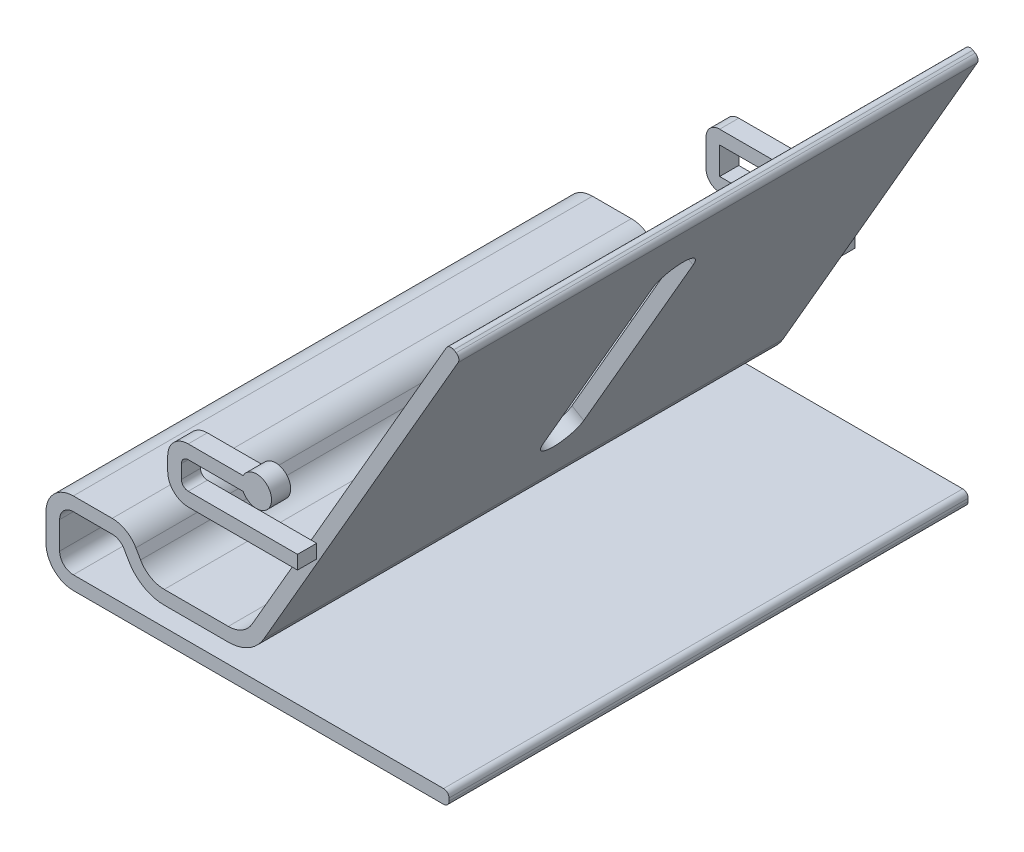
from build123d import *

# Parameters (mm, degrees)
EXTRUDE_12_DEPTH    = 190
CUT_EXTRUDE_1_REACH = 78.573
SKETCH_3_12_R       = 5.5
EXTRUDE_13_DEPTH    = 7
EXTRUDE_14_DEPTH    = 7
EXTRUDE_16_DEPTH    = 7


with BuildPart() as part:
    # Sketch 3 → Extrude 12 (new body)
    with BuildSketch(Plane.XY):
        with BuildLine():
            ThreePointArc((74, 128.17175976), (75.214412717, 129.103611413), (76.732050808, 128.903810568))
            Line((76.732050808, 128.903810568), (77.598076211, 128.403810568))
            ThreePointArc((77.598076211, 128.403810568), (78.529927864, 127.18939785), (78.330127019, 125.67175976))
            Line((78.330127019, 125.67175976), (7.216878365, 2.5))
            ThreePointArc((7.216878365, 2.5), (1.726497308, -2.990381057), (-5.773502692, -5))
            Line((-5.773502692, -5), (-29.226497308, -5))
            ThreePointArc((-29.226497308, -5), (-36.726497308, -2.990381057), (-42.216878365, 2.5))
            Line((-42.216878365, 2.5), (-43.943375673, 5.490381057))
            ThreePointArc((-43.943375673, 5.490381057), (-45.773502692, 7.320508076), (-48.273502692, 7.990381057))
            Line((-48.273502692, 7.990381057), (-62.5, 7.990381057))
            ThreePointArc((-62.5, 7.990381057), (-66.035533906, 6.525914963), (-67.5, 2.990381057))
            Line((-67.5, 2.990381057), (-67.5, -7.009618943))
            ThreePointArc((-67.5, -7.009618943), (-66.035533906, -10.545152849), (-62.5, -12.009618943))
            Line((-62.5, -12.009618943), (73, -12.009618943))
            ThreePointArc((73, -12.009618943), (74.414213562, -12.595405381), (75, -14.009618943))
            Line((75, -14.009618943), (75, -15.009618943))
            ThreePointArc((75, -15.009618943), (74.414213562, -16.423832506), (73, -17.009618943))
            Line((73, -17.009618943), (-62.5, -17.009618943))
            ThreePointArc((-62.5, -17.009618943), (-69.571067812, -14.080686755), (-72.5, -7.009618943))
            Line((-72.5, -7.009618943), (-72.5, 2.990381057))
            ThreePointArc((-72.5, 2.990381057), (-69.571067812, 10.061448869), (-62.5, 12.990381057))
            Line((-62.5, 12.990381057), (-48.273502692, 12.990381057))
            ThreePointArc((-48.273502692, 12.990381057), (-43.273502692, 11.650635095), (-39.613248654, 7.990381057))
            Line((-39.613248654, 7.990381057), (-37.886751346, 5))
            ThreePointArc((-37.886751346, 5), (-34.226497308, 1.339745962), (-29.226497308, 0))
            Line((-29.226497308, 0), (-5.773502692, 0))
            ThreePointArc((-5.773502692, 0), (-0.773502692, 1.339745962), (2.886751346, 5))
            Line((2.886751346, 5), (74, 128.17175976))
        make_face()
    extrude(amount=-EXTRUDE_12_DEPTH)

    # Sketch 19 → Cut-Extrude 1 (cut, up to next)
    with BuildSketch(Plane(origin=(0, 0, 0), x_dir=(0, 0, 1), z_dir=(-0.866025404, 0.5, 0)), mode=Mode.PRIVATE) as cut_extrude_1_sk1:
        with BuildLine():
            Line((-95, 107.5), (-95, 115))
            Line((-95, 115), (-102.5, 115))
            ThreePointArc((-102.5, 115), (-100.303300859, 109.696699141), (-95, 107.5))
        make_face()
    cut_extrude_1_tool1 = extrude(cut_extrude_1_sk1.sketch, amount=-CUT_EXTRUDE_1_REACH, mode=Mode.PRIVATE) & part.part
    add(cut_extrude_1_tool1.solids().sort_by_distance((55.908451, 96.836277, -98.183099))[0], mode=Mode.SUBTRACT)
    # Sketch 19 → Cut-Extrude 1 (cut, up to next)
    with BuildSketch(Plane(origin=(0, 0, 0), x_dir=(0, 0, 1), z_dir=(-0.866025404, 0.5, 0)), mode=Mode.PRIVATE) as cut_extrude_1_sk2:
        with BuildLine():
            Line((-87.5, 115), (-95, 115))
            Line((-95, 115), (-95, 107.5))
            ThreePointArc((-95, 107.5), (-89.696699141, 109.696699141), (-87.5, 115))
        make_face()
    cut_extrude_1_tool2 = extrude(cut_extrude_1_sk2.sketch, amount=-CUT_EXTRUDE_1_REACH, mode=Mode.PRIVATE) & part.part
    add(cut_extrude_1_tool2.solids().sort_by_distance((55.908451, 96.836277, -91.816901))[0], mode=Mode.SUBTRACT)
    # Sketch 19 → Cut-Extrude 1 (cut, up to next)
    with BuildSketch(Plane(origin=(0, 0, 0), x_dir=(0, 0, 1), z_dir=(-0.866025404, 0.5, 0)), mode=Mode.PRIVATE) as cut_extrude_1_sk3:
        with BuildLine():
            Line((-102.5, 115), (-95, 115))
            Line((-95, 115), (-87.5, 115))
            ThreePointArc((-87.5, 115), (-95, 122.5), (-102.5, 115))
        make_face()
    cut_extrude_1_tool3 = extrude(cut_extrude_1_sk3.sketch, amount=-CUT_EXTRUDE_1_REACH, mode=Mode.PRIVATE) & part.part
    add(cut_extrude_1_tool3.solids().sort_by_distance((59.091549, 102.349566, -95))[0], mode=Mode.SUBTRACT)
    # Sketch 19 → Cut-Extrude 1 (cut, up to next)
    with BuildSketch(Plane(origin=(0, 0, 0), x_dir=(0, 0, 1), z_dir=(-0.866025404, 0.5, 0)), mode=Mode.PRIVATE) as cut_extrude_1_sk4:
        with BuildLine():
            ThreePointArc((-95, 107.5), (-100.303300859, 109.696699141), (-102.5, 115))
            Line((-102.5, 115), (-102.5, 35))
            ThreePointArc((-102.5, 35), (-100.303300859, 40.303300859), (-95, 42.5))
            Line((-95, 42.5), (-95, 107.5))
        make_face()
    cut_extrude_1_tool4 = extrude(cut_extrude_1_sk4.sketch, amount=-CUT_EXTRUDE_1_REACH, mode=Mode.PRIVATE) & part.part
    add(cut_extrude_1_tool4.solids().sort_by_distance((37.5, 64.951905, -98.8479))[0], mode=Mode.SUBTRACT)
    # Sketch 19 → Cut-Extrude 1 (cut, up to next)
    with BuildSketch(Plane(origin=(0, 0, 0), x_dir=(0, 0, 1), z_dir=(-0.866025404, 0.5, 0)), mode=Mode.PRIVATE) as cut_extrude_1_sk5:
        with BuildLine():
            ThreePointArc((-87.5, 115), (-89.696699141, 109.696699141), (-95, 107.5))
            Line((-95, 107.5), (-95, 42.5))
            ThreePointArc((-95, 42.5), (-89.696699141, 40.303300859), (-87.5, 35))
            Line((-87.5, 35), (-87.5, 115))
        make_face()
    cut_extrude_1_tool5 = extrude(cut_extrude_1_sk5.sketch, amount=-CUT_EXTRUDE_1_REACH, mode=Mode.PRIVATE) & part.part
    add(cut_extrude_1_tool5.solids().sort_by_distance((37.5, 64.951905, -91.1521))[0], mode=Mode.SUBTRACT)
    # Sketch 19 → Cut-Extrude 1 (cut, up to next)
    with BuildSketch(Plane(origin=(0, 0, 0), x_dir=(0, 0, 1), z_dir=(-0.866025404, 0.5, 0)), mode=Mode.PRIVATE) as cut_extrude_1_sk6:
        with BuildLine():
            ThreePointArc((-95, 42.5), (-100.303300859, 40.303300859), (-102.5, 35))
            Line((-102.5, 35), (-95, 35))
            Line((-95, 35), (-95, 42.5))
        make_face()
    cut_extrude_1_tool6 = extrude(cut_extrude_1_sk6.sketch, amount=-CUT_EXTRUDE_1_REACH, mode=Mode.PRIVATE) & part.part
    add(cut_extrude_1_tool6.solids().sort_by_distance((19.091549, 33.067534, -98.183099))[0], mode=Mode.SUBTRACT)
    # Sketch 19 → Cut-Extrude 1 (cut, up to next)
    with BuildSketch(Plane(origin=(0, 0, 0), x_dir=(0, 0, 1), z_dir=(-0.866025404, 0.5, 0)), mode=Mode.PRIVATE) as cut_extrude_1_sk7:
        with BuildLine():
            Line((-95, 35), (-102.5, 35))
            ThreePointArc((-102.5, 35), (-95, 27.5), (-87.5, 35))
            Line((-87.5, 35), (-95, 35))
        make_face()
    cut_extrude_1_tool7 = extrude(cut_extrude_1_sk7.sketch, amount=-CUT_EXTRUDE_1_REACH, mode=Mode.PRIVATE) & part.part
    add(cut_extrude_1_tool7.solids().sort_by_distance((15.908451, 27.554245, -95))[0], mode=Mode.SUBTRACT)
    # Sketch 19 → Cut-Extrude 1 (cut, up to next)
    with BuildSketch(Plane(origin=(0, 0, 0), x_dir=(0, 0, 1), z_dir=(-0.866025404, 0.5, 0)), mode=Mode.PRIVATE) as cut_extrude_1_sk8:
        with BuildLine():
            ThreePointArc((-87.5, 35), (-89.696699141, 40.303300859), (-95, 42.5))
            Line((-95, 42.5), (-95, 35))
            Line((-95, 35), (-87.5, 35))
        make_face()
    cut_extrude_1_tool8 = extrude(cut_extrude_1_sk8.sketch, amount=-CUT_EXTRUDE_1_REACH, mode=Mode.PRIVATE) & part.part
    add(cut_extrude_1_tool8.solids().sort_by_distance((19.091549, 33.067534, -91.816901))[0], mode=Mode.SUBTRACT)



with BuildPart() as body_2:
    # Sketch 3_12 → Extrude 13 (new body)
    with BuildSketch(Plane.XY):
        with Locations((11.547005384, 55)):
            Circle(SKETCH_3_12_R)
    extrude(amount=EXTRUDE_13_DEPTH)


with BuildPart() as part_1:
    add(part.part)

    add(body_2.part)  # Extrude 14 merges body 2
    # Sketch 20 → Extrude 14 (add)
    with BuildSketch(Plane.XY):
        with BuildLine():
            Line((-13.452994616, 55), (11.547005384, 55))
            Line((11.547005384, 55), (11.547005384, 57.5))
            Line((11.547005384, 57.5), (-13.452994616, 57.5))
            ThreePointArc((-13.452994616, 57.5), (-18.756295475, 55.303300859), (-20.952994616, 50))
            Line((-20.952994616, 50), (-20.952994616, 45))
            ThreePointArc((-20.952994616, 45), (-18.756295475, 39.696699141), (-13.452994616, 37.5))
            Line((-13.452994616, 37.5), (26.547005384, 37.5))
            Line((26.547005384, 37.5), (26.547005384, 40))
            Line((26.547005384, 40), (-13.452994616, 40))
            ThreePointArc((-13.452994616, 40), (-16.988528522, 41.464466094), (-18.452994616, 45))
            Line((-18.452994616, 45), (-18.452994616, 50))
            ThreePointArc((-18.452994616, 50), (-16.988528522, 53.535533906), (-13.452994616, 55))
        make_face()
        with BuildLine():
            Line((11.547005384, 52.5), (11.547005384, 55))
            Line((11.547005384, 55), (-13.452994616, 55))
            ThreePointArc((-13.452994616, 55), (-16.988528522, 53.535533906), (-18.452994616, 50))
            Line((-18.452994616, 50), (-18.452994616, 45))
            ThreePointArc((-18.452994616, 45), (-16.988528522, 41.464466094), (-13.452994616, 40))
            Line((-13.452994616, 40), (26.547005384, 40))
            Line((26.547005384, 40), (26.547005384, 42.5))
            Line((26.547005384, 42.5), (-13.452994616, 42.5))
            ThreePointArc((-13.452994616, 42.5), (-15.220761569, 43.232233047), (-15.952994616, 45))
            Line((-15.952994616, 45), (-15.952994616, 50))
            ThreePointArc((-15.952994616, 50), (-15.220761569, 51.767766953), (-13.452994616, 52.5))
            Line((-13.452994616, 52.5), (11.547005384, 52.5))
        make_face()
    extrude(amount=EXTRUDE_14_DEPTH)

    # Sketch 21 → Extrude 16 (add)
    with BuildSketch(Plane(origin=(0, 0, -190), x_dir=(-1, 0, 0), z_dir=(0, 0, -1))):
        with BuildLine():
            Line((-11.547005384, 52.5), (-11.547005384, 55))
            Line((-11.547005384, 55), (-11.547005384, 57.5))
            Line((-11.547005384, 57.5), (-6.648025898, 57.5))
            ThreePointArc((-6.648025898, 57.5), (-17.047005384, 55), (-6.648025898, 52.5))
            Line((-6.648025898, 52.5), (-11.547005384, 52.5))
        make_face()
        with BuildLine():
            Line((-11.547005384, 57.5), (-11.547005384, 55))
            Line((-11.547005384, 55), (-6.047005384, 55))
            ThreePointArc((-6.047005384, 55), (-6.199370992, 56.285615189), (-6.648025898, 57.5))
            Line((-6.648025898, 57.5), (-11.547005384, 57.5))
        make_face()
        with BuildLine():
            Line((-6.047005384, 55), (-11.547005384, 55))
            Line((-11.547005384, 55), (-11.547005384, 52.5))
            Line((-11.547005384, 52.5), (-6.648025898, 52.5))
            ThreePointArc((-6.648025898, 52.5), (-6.199370992, 53.714384811), (-6.047005384, 55))
        make_face()
        with BuildLine():
            ThreePointArc((-6.648025898, 57.5), (-6.199370992, 56.285615189), (-6.047005384, 55))
            Line((-6.047005384, 55), (15.952994616, 55))
            ThreePointArc((15.952994616, 55), (17.720761569, 54.267766953), (18.452994616, 52.5))
            Line((18.452994616, 52.5), (18.452994616, 42.5))
            ThreePointArc((18.452994616, 42.5), (17.720761569, 40.732233047), (15.952994616, 40))
            Line((15.952994616, 40), (-23.094010768, 40))
            Line((-23.094010768, 40), (-21.650635095, 37.5))
            Line((-21.650635095, 37.5), (15.952994616, 37.5))
            ThreePointArc((15.952994616, 37.5), (19.488528522, 38.964466094), (20.952994616, 42.5))
            Line((20.952994616, 42.5), (20.952994616, 52.5))
            ThreePointArc((20.952994616, 52.5), (19.488528522, 56.035533906), (15.952994616, 57.5))
            Line((15.952994616, 57.5), (-6.648025898, 57.5))
        make_face()
        with BuildLine():
            Line((15.952994616, 55), (-6.047005384, 55))
            ThreePointArc((-6.047005384, 55), (-6.199370992, 53.714384811), (-6.648025898, 52.5))
            Line((-6.648025898, 52.5), (15.952994616, 52.5))
            Line((15.952994616, 52.5), (15.952994616, 42.5))
            Line((15.952994616, 42.5), (-24.537386441, 42.5))
            Line((-24.537386441, 42.5), (-23.094010768, 40))
            Line((-23.094010768, 40), (15.952994616, 40))
            ThreePointArc((15.952994616, 40), (17.720761569, 40.732233047), (18.452994616, 42.5))
            Line((18.452994616, 42.5), (18.452994616, 52.5))
            ThreePointArc((18.452994616, 52.5), (17.720761569, 54.267766953), (15.952994616, 55))
        make_face()
        Polygon((-23.094010768, 40), (-24.537386441, 42.5), (-26.547005384, 42.5), (-26.547005384, 40), align=None)
        Polygon((-21.650635095, 37.5), (-23.094010768, 40), (-26.547005384, 40), (-26.547005384, 37.5), align=None)
    extrude(amount=EXTRUDE_16_DEPTH)


solid = part_1.part
